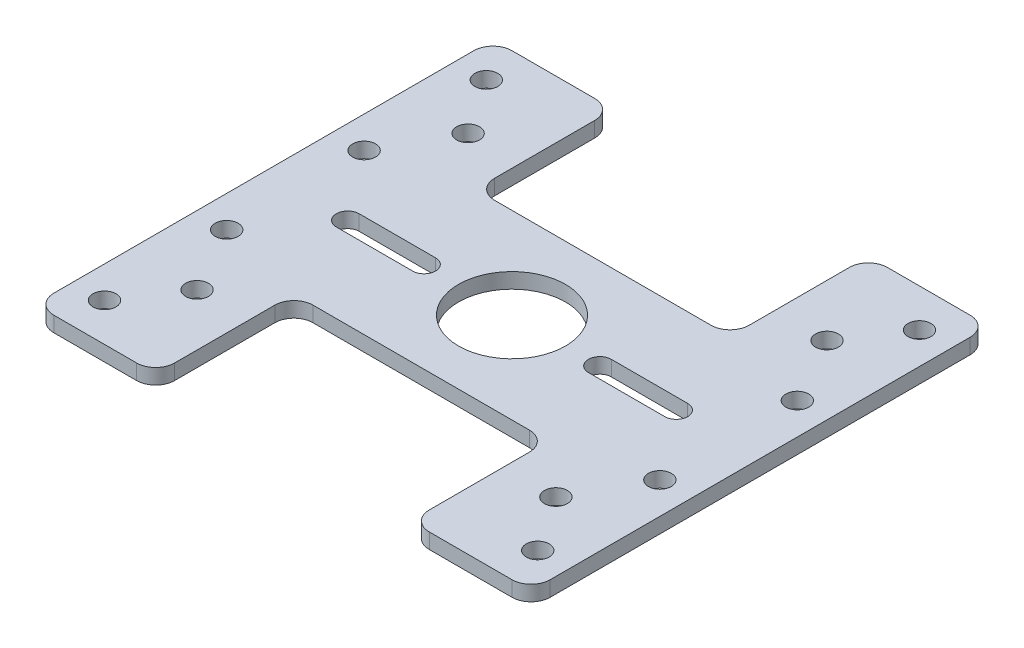
from build123d import *

# Parameters (mm, degrees)
SKETCH_1_W                = 65
SKETCH_1_H                = 60
EXTRUDE_1_DEPTH           = 2
SKETCH_2_R                = 1.5
CUT_EXTRUDE_1_DEPTH       = 2
SKETCH_5_R                = 7
CUT_EXTRUDE_4_DEPTH       = 3
SKETCH_6_R                = 1.5
CUT_EXTRUDE_5_DEPTH       = 3
CUT_EXTRUDE_6_DEPTH       = 3
SKETCH_8_R                = 1.5
CUT_EXTRUDE_7_DEPTH       = 3
MIRROR_8_COPY_1_SKETCH_R  = 1.5
MIRROR_8_COPY_1_DEPTH     = 3
MIRROR_10_COPY_1_SKETCH_R = 1.5
MIRROR_10_COPY_1_DEPTH    = 2
MIRROR_10_COPY_2_SKETCH_R = 1.5
MIRROR_10_COPY_2_DEPTH    = 3
SKETCH_9_W                = 33.344360542
SKETCH_9_H                = 36.22087855
CUT_EXTRUDE_8_DEPTH       = 3
FILLET_1_R                = 2.5


with BuildPart() as part:
    # 草图1 → 凸台-拉伸1 (new body)
    with BuildSketch(Plane(origin=(0, 0, 0), x_dir=(1, 0, 0), z_dir=(0, 1, 0))):
        Rectangle(SKETCH_1_W, SKETCH_1_H)
    extrude(amount=EXTRUDE_1_DEPTH)

    # 草图2 → 切除-拉伸1 (cut)
    with BuildSketch(Plane(origin=(0, 2, 0), x_dir=(1, 0, 0), z_dir=(0, 1, 0))):
        with Locations((-28.367832783, 25)):
            Circle(SKETCH_2_R)
    cut_extrude_1 = extrude(amount=-CUT_EXTRUDE_1_DEPTH, mode=Mode.SUBTRACT)

    # 草图5 → 切除-拉伸4 (cut, through all)
    with BuildSketch(Plane(origin=(0, 2, 0), x_dir=(1, 0, 0), z_dir=(0, 1, 0))):
        Circle(SKETCH_5_R)
    extrude(amount=-CUT_EXTRUDE_4_DEPTH, mode=Mode.SUBTRACT)

    # 草图6 → 切除-拉伸5 (cut, through all)
    with BuildSketch(Plane(origin=(0, 2, 0), x_dir=(1, 0, 0), z_dir=(0, 1, 0))):
        with Locations((-28.367832783, -9)):
            Circle(SKETCH_6_R)
    cut_extrude_5 = extrude(amount=-CUT_EXTRUDE_5_DEPTH, mode=Mode.SUBTRACT)

    # 镜向7: 切除-拉伸5 across plane
    add(cut_extrude_5.mirror(Plane.XY), mode=Mode.SUBTRACT)

    # 草图7 → 切除-拉伸6 (cut, through all)
    with BuildSketch(Plane(origin=(0, 2, 0), x_dir=(1, 0, 0), z_dir=(0, 1, 0))):
        with BuildLine():
            Line((-11.509285997, 1.5), (-21.509285997, 1.5))
            ThreePointArc((-21.509285997, 1.5), (-23.009285997, 0), (-21.509285997, -1.5))
            Line((-21.509285997, -1.5), (-11.509285997, -1.5))
            ThreePointArc((-11.509285997, -1.5), (-10.009285997, 0), (-11.509285997, 1.5))
        make_face()
    cut_extrude_6 = extrude(amount=-CUT_EXTRUDE_6_DEPTH, mode=Mode.SUBTRACT)

    # 草图8 → 切除-拉伸7 (cut, through all)
    with BuildSketch(Plane(origin=(0, 2, 0), x_dir=(1, 0, 0), z_dir=(0, 1, 0))):
        with Locations((23.5, 17.75)):
            Circle(SKETCH_8_R)
    cut_extrude_7 = extrude(amount=-CUT_EXTRUDE_7_DEPTH, mode=Mode.SUBTRACT)

    # 镜向8: 切除-拉伸6, 切除-拉伸5 across plane
    add(cut_extrude_6.mirror(Plane(origin=(0, 0, 0), x_dir=(0, 0, 1), z_dir=(1, 0, 0))), mode=Mode.SUBTRACT)
    add(cut_extrude_5.mirror(Plane(origin=(0, 0, 0), x_dir=(0, 0, 1), z_dir=(1, 0, 0))), mode=Mode.SUBTRACT)

    # 镜向8 copy 1 sketch → 镜向8 copy 1 (cut, through all)
    with BuildSketch(Plane(origin=(0, 2, 0), x_dir=(-1, 0, 0), z_dir=(0, 1, 0))):
        with Locations((-28.367832783, -9)):
            Circle(MIRROR_8_COPY_1_SKETCH_R)
    extrude(amount=-MIRROR_8_COPY_1_DEPTH, mode=Mode.SUBTRACT)

    # 镜向9: 切除-拉伸1, 切除-拉伸7 across plane
    add(cut_extrude_1.mirror(Plane.XY), mode=Mode.SUBTRACT)
    add(cut_extrude_7.mirror(Plane.XY), mode=Mode.SUBTRACT)

    # 镜向10: 切除-拉伸1, 切除-拉伸7 across plane
    add(cut_extrude_1.mirror(Plane(origin=(0, 0, 0), x_dir=(0, 0, 1), z_dir=(1, 0, 0))), mode=Mode.SUBTRACT)
    add(cut_extrude_7.mirror(Plane(origin=(0, 0, 0), x_dir=(0, 0, 1), z_dir=(1, 0, 0))), mode=Mode.SUBTRACT)

    # 镜向10 copy 1 sketch → 镜向10 copy 1 (cut)
    with BuildSketch(Plane(origin=(0, 2, 0), x_dir=(-1, 0, 0), z_dir=(0, 1, 0))):
        with Locations((-28.367832783, 25)):
            Circle(MIRROR_10_COPY_1_SKETCH_R)
    extrude(amount=-MIRROR_10_COPY_1_DEPTH, mode=Mode.SUBTRACT)

    # 镜向10 copy 2 sketch → 镜向10 copy 2 (cut, through all)
    with BuildSketch(Plane(origin=(0, 2, 0), x_dir=(-1, 0, 0), z_dir=(0, 1, 0))):
        with Locations((23.5, 17.75)):
            Circle(MIRROR_10_COPY_2_SKETCH_R)
    extrude(amount=-MIRROR_10_COPY_2_DEPTH, mode=Mode.SUBTRACT)

    # 草图9 → 切除-拉伸8 (cut, through all)
    with BuildSketch(Plane(origin=(0, 2, 0), x_dir=(1, 0, 0), z_dir=(0, 1, 0))):
        with Locations((0, 30)):
            Rectangle(SKETCH_9_W, SKETCH_9_H)
    cut_extrude_8 = extrude(amount=-CUT_EXTRUDE_8_DEPTH, mode=Mode.SUBTRACT)

    # 镜向11: 切除-拉伸8 across plane
    add(cut_extrude_8.mirror(Plane.XY), mode=Mode.SUBTRACT)

    # 圆角1
    fillet_1_edges = [part.edges().sort_by_distance(p)[0] for p in [
        (16.672180271, 1, -30),
        (-16.672180271, 1, -30),
        (-16.672180271, 1, -11.889560725),
        (16.672180271, 1, -11.889560725),
        (16.672180271, 1, 30),
        (-16.672180271, 1, 30),
        (16.672180271, 1, 11.889560725),
        (-16.672180271, 1, 11.889560725),
        (-32.5, 1, -30),
        (32.5, 1, -30),
        (32.5, 1, 30),
        (-32.5, 1, 30),
    ]]
    fillet(fillet_1_edges, radius=FILLET_1_R)


solid = part.part
